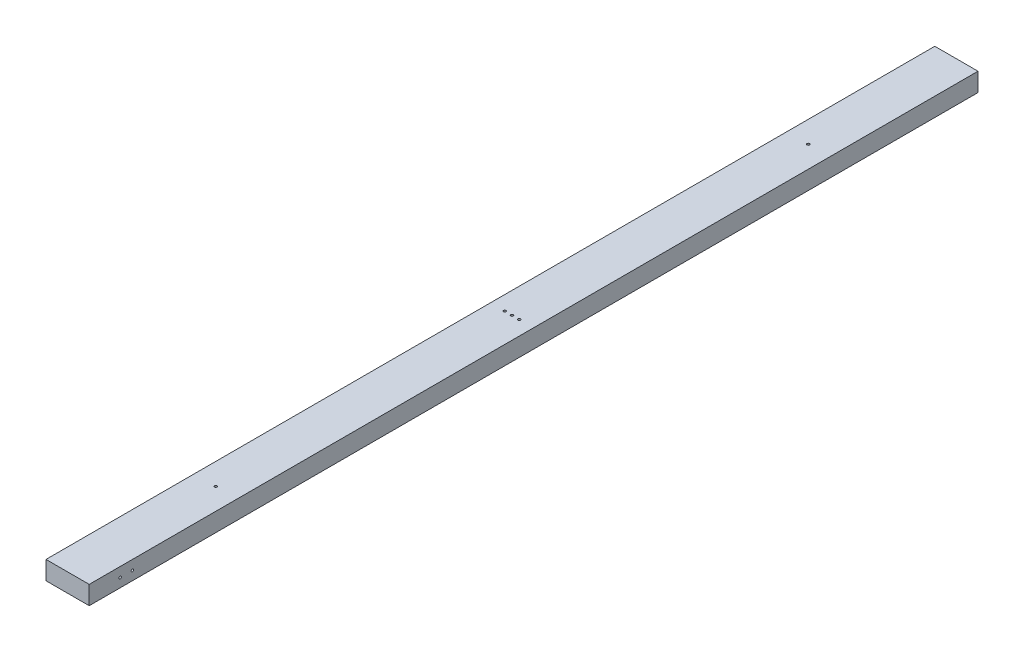
from build123d import *

# Parameters (mm, degrees)
SKETCH1_W           = 88.9
SKETCH1_H           = 38.1
BOSS_EXTRUDE1_DEPTH = 1828.8
SKETCH2_R           = 2.5796875
CUT_EXTRUDE1_DEPTH  = 89.9
SKETCH3_R           = 2.5796875
CUT_EXTRUDE2_DEPTH  = 39.1
SKETCH4_R           = 2.5796875
CUT_EXTRUDE3_DEPTH  = 39.1


with BuildPart() as part:
    # Sketch1 → Boss-Extrude1 (new body)
    with BuildSketch(Plane.XY):
        with Locations((20.220860341, 0.753389831)):
            Rectangle(SKETCH1_W, SKETCH1_H)
    extrude(amount=BOSS_EXTRUDE1_DEPTH)

    # Sketch2 → Cut-Extrude1 (cut, through all)
    with BuildSketch(Plane.ZY.offset(24.229139659)):
        with Locations((1739.9, 0)):
            Circle(SKETCH2_R)
        with Locations((1765.3, 0)):
            Circle(SKETCH2_R)
    extrude(amount=-CUT_EXTRUDE1_DEPTH, mode=Mode.SUBTRACT)

    # Sketch3 → Cut-Extrude2 (cut, through all)
    with BuildSketch(Plane.XZ.offset(18.296610169)):
        with Locations((35.037527007, 914.4)):
            Circle(SKETCH3_R)
        with Locations((5.404193674, 914.4)):
            Circle(SKETCH3_R)
    extrude(amount=-CUT_EXTRUDE2_DEPTH, mode=Mode.SUBTRACT)

    # Sketch4 → Cut-Extrude3 (cut, through all)
    with BuildSketch(Plane.XZ.offset(18.296610169)):
        with Locations((20.220860341, 1524)):
            Circle(SKETCH4_R)
        with Locations((20.220860341, 914.4)):
            Circle(SKETCH4_R)
        with Locations((20.220860341, 304.8)):
            Circle(SKETCH4_R)
    extrude(amount=-CUT_EXTRUDE3_DEPTH, mode=Mode.SUBTRACT)


solid = part.part
